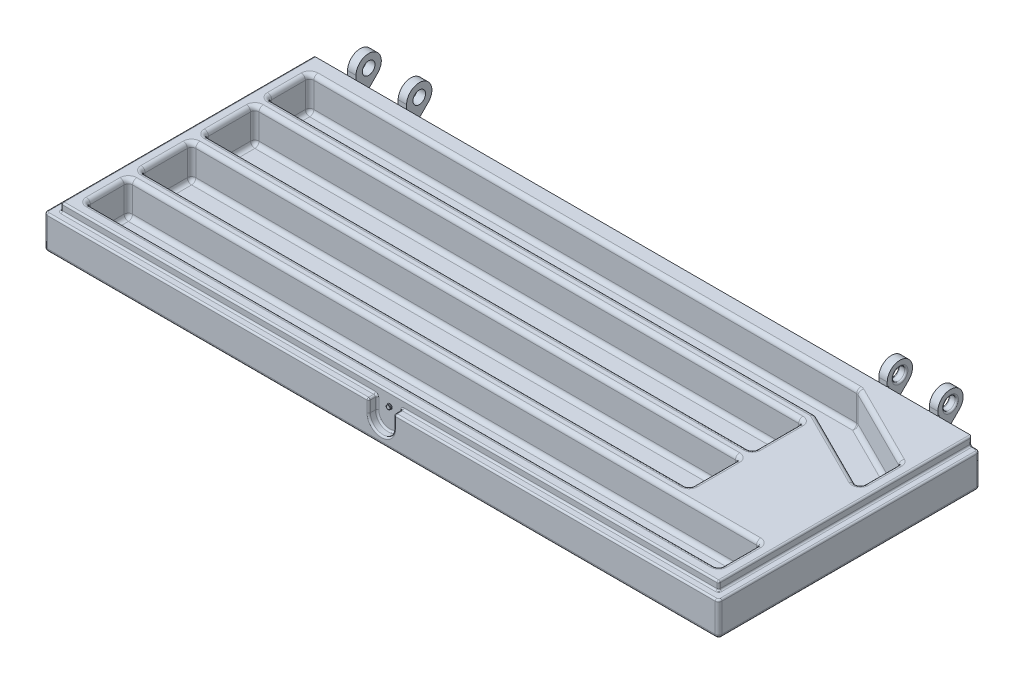
from build123d import *

# Parameters (mm, degrees)
SKETCH_1_W          = 160
SKETCH_1_H          = 62
EXTRUDE_1_DEPTH     = 10
SKETCH_2_W          = 150
SKETCH_2_H          = 10
SKETCH_2_W_2        = 130
SKETCH_2_H_2        = 12
CUT_EXTRUDE_1_DEPTH = 8
SKETCH_3_R          = 1.5
EXTRUDE_2_DEPTH     = 2
SKETCH_5_R          = 1.5
EXTRUDE_3_DEPTH     = 2
CUT_EXTRUDE_2_DEPTH = 2
CUT_EXTRUDE_3_DEPTH = 2
SKETCH_8_R          = 0.5
EXTRUDE_4_DEPTH     = 0.4
FILLET_1_R          = 0.8
FILLET_2_R          = 0.4
FILLET_3_R          = 1
FILLET_4_R          = 0.1


with BuildPart() as part:
    # 草图1 → 凸台-拉伸1 (new body)
    with BuildSketch(Plane(origin=(0, 0, 0), x_dir=(1, 0, 0), z_dir=(0, 1, 0))):
        with Locations((80, 31)):
            Rectangle(SKETCH_1_W, SKETCH_1_H)
    extrude(amount=EXTRUDE_1_DEPTH)

    # 草图2 → 切除-拉伸1 (cut)
    with BuildSketch(Plane(origin=(0, 10, 0), x_dir=(1, 0, 0), z_dir=(0, 1, 0))):
        with Locations((80, 10)):
            Rectangle(SKETCH_2_W, SKETCH_2_H)
        with Locations((70, 24)):
            Rectangle(SKETCH_2_W_2, SKETCH_2_H_2)
        with Locations((70, 39)):
            Rectangle(SKETCH_2_W_2, SKETCH_2_H_2)
        Polygon((5, 48), (135, 48), (155, 38), (155, 48), (135, 58), (5, 58), align=None)
    extrude(amount=-CUT_EXTRUDE_1_DEPTH, mode=Mode.SUBTRACT)

    # 草图3 → 凸台-拉伸2 (add)
    with BuildSketch(Plane(origin=(150, 0, 0), x_dir=(0, 0, -1), z_dir=(1, 0, 0))):
        with BuildLine():
            Line((62, 11), (62, 3.757359313))
            Line((62, 3.757359313), (67.121320344, 8.878679656))
            ThreePointArc((67.121320344, 8.878679656), (66.148050297, 13.771638598), (62, 11))
        make_face()
        with Locations((65, 11)):
            Circle(SKETCH_3_R, mode=Mode.SUBTRACT)
    extrude_2 = extrude(amount=-EXTRUDE_2_DEPTH)

    # 草图5 → 凸台-拉伸3 (add)
    with BuildSketch(Plane.ZY.offset(-136)):
        with BuildLine():
            Line((-62, 10), (-62, 11))
            ThreePointArc((-62, 11), (-66.148050297, 13.771638598), (-67.121320344, 8.878679656))
            Line((-67.121320344, 8.878679656), (-62, 3.757359313))
            Line((-62, 3.757359313), (-62, 10))
        make_face()
        with Locations((-65, 11)):
            Circle(SKETCH_5_R, mode=Mode.SUBTRACT)
    extrude_3 = extrude(amount=-EXTRUDE_3_DEPTH)

    # 镜向1: 凸台-拉伸2, 凸台-拉伸3 across plane
    add(extrude_2.mirror(Plane(origin=(80, 0, 0), x_dir=(0, 0, 1), z_dir=(1, 0, 0))))
    add(extrude_3.mirror(Plane(origin=(80, 0, 0), x_dir=(0, 0, 1), z_dir=(1, 0, 0))))

    # 草图6 → 切除-拉伸2 (cut)
    with BuildSketch(Plane(origin=(0, 10, 0), x_dir=(1, 0, 0), z_dir=(0, 1, 0))):
        Polygon((0, 62), (0, 0), (160, 0), (160, 62), (158, 62), (158, 2), (2, 2), (2, 62), align=None)
    extrude(amount=-CUT_EXTRUDE_2_DEPTH, mode=Mode.SUBTRACT)

    # 草图7 → 切除-拉伸3 (cut)
    with BuildSketch(Plane.XY):
        with BuildLine():
            Line((83, 5), (83, 8))
            Line((83, 8), (77, 8))
            Line((77, 8), (77, 5))
            ThreePointArc((77, 5), (80, 2), (83, 5))
        make_face()
    extrude(amount=-CUT_EXTRUDE_3_DEPTH, mode=Mode.SUBTRACT)

    # 草图8 → 凸台-拉伸4 (add)
    with BuildSketch(Plane.XY.offset(-2)):
        with Locations((80, 7)):
            Circle(SKETCH_8_R)
    extrude(amount=EXTRUDE_4_DEPTH)

    # 圆角1
    fillet_1_edges = [part.edges().sort_by_distance(p)[0] for p in [
        (160, 4, -62),
        (160, 4, 0),
        (0, 4, 0),
        (0, 4, -62),
        (80, 0, -62),
        (160, 0, -31),
        (80, 0, 0),
        (0, 0, -31),
    ]]
    fillet(fillet_1_edges, radius=FILLET_1_R)

    # 圆角2
    fillet_2_edges = [part.edges().sort_by_distance(p)[0] for p in [
        (1.4, 8, -62),
        (2, 8, -32),
        (2, 9, -62),
        (120.5, 8, -2),
        (2, 9, -2),
        (158, 8, -32),
        (158, 9, -2),
        (158, 9, -62),
        (158, 10, -32),
        (80, 10, -2),
        (2, 10, -32),
        (121.1, 8, 0),
        (39.5, 8, -2),
        (80, 2, 0),
        (83, 6.5, 0),
        (77, 6.5, 0),
        (83, 6.5, -2),
        (83, 8, -1),
        (77, 8, -1),
        (77, 6.5, -2),
        (80, 2, -2),
        (38.9, 8, 0),
        (160, 8, -31),
        (158.6, 8, -62),
        (0, 8, -31),
        (0.234314575, 8, -61.765685425),
        (0.234314575, 8, -0.234314575),
        (159.765685425, 8, -61.765685425),
        (159.765685425, 8, -0.234314575),
        (149, 3.757359313, -62),
        (150, 6.878679656, -62),
        (150, 11, -63.5),
        (148, 6.878679656, -62),
        (148, 11, -63.5),
        (138, 6.878679656, -62),
        (137, 3.757359313, -62),
        (136, 11, -66.5),
        (138, 11, -66.5),
        (136, 6.878679656, -62),
    ]]
    fillet(fillet_2_edges, radius=FILLET_2_R)

    # 圆角3
    fillet_3_edges = [part.edges().sort_by_distance(p)[0] for p in [
        (5, 2, -10),
        (5, 6, -5),
        (80, 2, -15),
        (5, 6, -15),
        (155, 2, -10),
        (155, 6, -15),
        (80, 2, -5),
        (155, 6, -5),
        (5, 10, -10),
        (80, 10, -5),
        (155, 10, -10),
        (80, 10, -15),
        (5, 2, -53),
        (5, 6, -48),
        (70, 2, -58),
        (5, 6, -58),
        (145, 2, -53),
        (135, 6, -58),
        (155, 2, -43),
        (155, 6, -48),
        (145, 2, -43),
        (155, 6, -38),
        (70, 2, -48),
        (135, 6, -48),
        (5, 10, -53),
        (70, 10, -48),
        (145, 10, -43),
        (155, 10, -43),
        (145, 10, -53),
        (70, 10, -58),
        (5, 2, -39),
        (5, 6, -33),
        (70, 2, -45),
        (5, 6, -45),
        (135, 2, -39),
        (135, 6, -45),
        (70, 2, -33),
        (135, 6, -33),
        (5, 10, -39),
        (70, 10, -33),
        (135, 10, -39),
        (70, 10, -45),
        (5, 2, -24),
        (5, 6, -18),
        (70, 2, -30),
        (5, 6, -30),
        (135, 2, -24),
        (135, 6, -30),
        (70, 2, -18),
        (135, 6, -18),
        (5, 10, -24),
        (70, 10, -18),
        (135, 10, -24),
        (70, 10, -30),
    ]]
    fillet(fillet_3_edges, radius=FILLET_3_R)

    # 圆角4
    fillet_4_edges = [part.edges().sort_by_distance(p)[0] for p in [
        (79.5, 7, -2),
        (79.5, 7, -1.6),
    ]]
    fillet(fillet_4_edges, radius=FILLET_4_R)


solid = part.part
